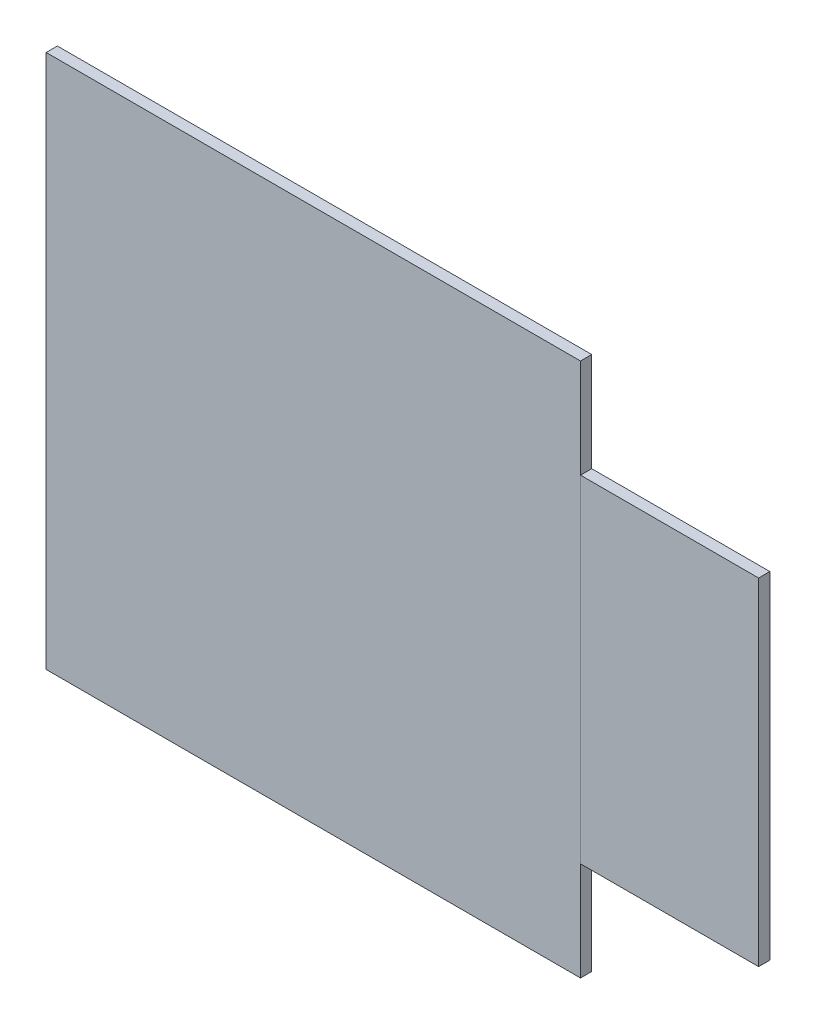
from build123d import *

# Parameters (mm, degrees)
SKETCH1_W           = 19.05
SKETCH1_H           = 19.05
BOSS_EXTRUDE1_DEPTH = 0.4
SKETCH2_W           = 6.35
SKETCH2_H           = 12
BOSS_EXTRUDE2_DEPTH = 0.4


with BuildPart() as part:
    # Sketch1 → Boss-Extrude1 (new body)
    with BuildSketch(Plane.XY):
        Rectangle(SKETCH1_W, SKETCH1_H)
    extrude(amount=BOSS_EXTRUDE1_DEPTH)


with BuildPart() as body_2:
    # Sketch2 → Boss-Extrude2 (new body)
    with BuildSketch(Plane.XY.offset(0.4)):
        with Locations((12.7, 0)):
            Rectangle(SKETCH2_W, SKETCH2_H)
    extrude(amount=-BOSS_EXTRUDE2_DEPTH)


solid = Compound([part.part, body_2.part])
